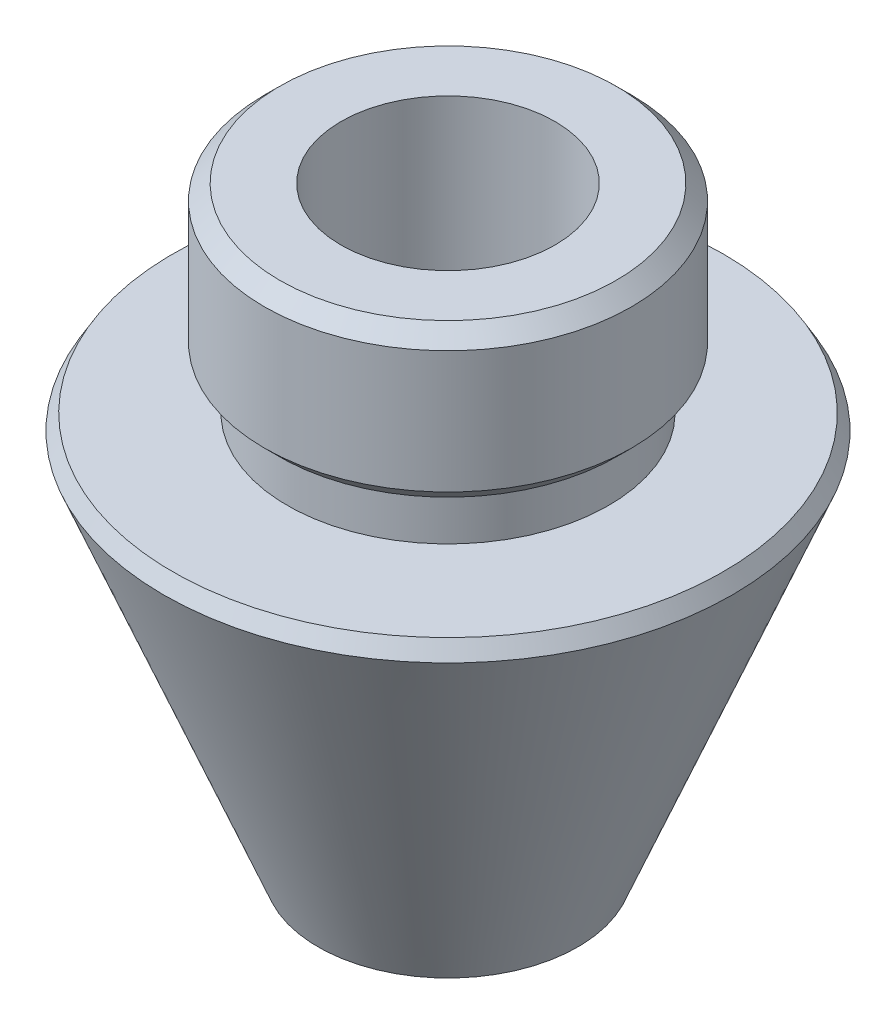
from build123d import *

# Parameters (mm, degrees)
CHANFRO1_SIZE = 1
CHANFRO2_SIZE = 1


with BuildPart() as part:
    # Esboço1 → Revolução1 (revolve)
    with BuildSketch(Plane(origin=(0, 0, 0), x_dir=(0, 0, -1), z_dir=(1, 0, 0))):
        Polygon((18, 18.768101913), (10.5, 18.768101913), (10.5, 21.768101913), (12, 21.768101913), (12, 31.768101913), (7, 31.768101913), (7, -7.231898087), (8.495318128, -7.231898087), (18.5883066, 17.749124991), align=None)
    revolve(axis=Axis((0, 0, 0), (0, 1, 0)))

    # Chanfro1
    chanfro1_edges = [part.edges().sort_by_distance(p)[0] for p in [
        (0, 31.768101913, 12),
    ]]
    chamfer(chanfro1_edges, length=CHANFRO1_SIZE)

    # Chanfro2
    chanfro2_edges = [part.edges().sort_by_distance(p)[0] for p in [
        (0, 21.768101913, 12),
    ]]
    chamfer(chanfro2_edges, length=CHANFRO2_SIZE)


solid = part.part
